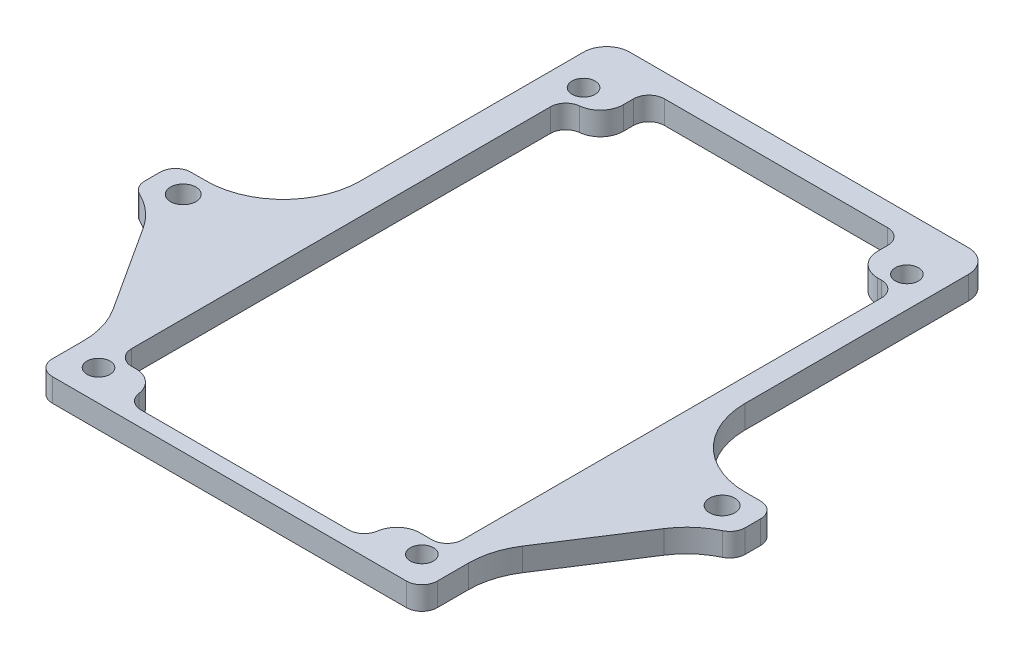
from build123d import *

# Parameters (mm, degrees)
SKETCH_1_R          = 1.65
SKETCH_1_R_2        = 1.5
EXTRUDE_1_DEPTH     = 3
FILLET_1_R          = 2
EXTRUDE_2_DEPTH     = 3
FILLET_2_R          = 10
SKETCH_3_W          = 43
SKETCH_3_H          = 4
EXTRUDE_3_DEPTH     = 3
FILLET_3_R          = 5
SKETCH_4_W          = 43
SKETCH_4_H          = 19.849699933
CUT_EXTRUDE_1_DEPTH = 10
FILLET_4_R          = 3
FILLET_5_R          = 3
FILLET_6_R          = 3
FILLET_7_R          = 3


with BuildPart() as part:
    # 草图1 → 凸台-拉伸1 (new body)
    with BuildSketch(Plane(origin=(0, 0, 0), x_dir=(1, 0, 0), z_dir=(0, 1, 0))):
        with BuildLine():
            Line((-37, 3), (-35, 3))
            ThreePointArc((-35, 3), (-27.928932188, 5.928932188), (-25, 13))
            Line((-25, 13), (-25, 42))
            ThreePointArc((-25, 42), (-24.121320344, 44.121320344), (-22, 45))
            Line((-22, 45), (22, 45))
            ThreePointArc((22, 45), (24.121320344, 44.121320344), (25, 42))
            Line((25, 42), (25, 13))
            ThreePointArc((25, 13), (27.928932188, 5.928932188), (35, 3))
            Line((35, 3), (37, 3))
            ThreePointArc((37, 3), (38.414213562, 2.414213562), (39, 1))
            Line((39, 1), (39, -1))
            ThreePointArc((39, -1), (38.414213562, -2.414213562), (37, -3))
            Line((37, -3), (35, -3))
            ThreePointArc((35, -3), (27.928932188, -5.928932188), (25, -13))
            Line((25, -13), (25, -27))
            ThreePointArc((25, -27), (24.414213562, -28.414213562), (23, -29))
            Line((23, -29), (-0.329591816, -29))
            Line((-0.329591816, -29), (-23, -29))
            ThreePointArc((-23, -29), (-24.414213562, -28.414213562), (-25, -27))
            Line((-25, -27), (-25, -13))
            ThreePointArc((-25, -13), (-27.928932188, -5.928932188), (-35, -3))
            Line((-35, -3), (-37, -3))
            ThreePointArc((-37, -3), (-38.414213562, -2.414213562), (-39, -1))
            Line((-39, -1), (-39, 1))
            ThreePointArc((-39, 1), (-38.414213562, 2.414213562), (-37, 3))
        make_face()
        with Locations((35, 0)):
            Circle(SKETCH_1_R, mode=Mode.SUBTRACT)
        with Locations((-35, 0)):
            Circle(SKETCH_1_R, mode=Mode.SUBTRACT)
        with Locations((21, 38)):
            Circle(SKETCH_1_R_2, mode=Mode.SUBTRACT)
        with Locations((21, -25)):
            Circle(SKETCH_1_R_2, mode=Mode.SUBTRACT)
        with Locations((-21, 38)):
            Circle(SKETCH_1_R_2, mode=Mode.SUBTRACT)
        with Locations((-21, -25)):
            Circle(SKETCH_1_R_2, mode=Mode.SUBTRACT)
        Polygon((-16.5, 42), (16.5, 42), (16.5, 35.7), (22, 35.7), (22, -22.7), (15.5, -22.7), (15.5, -27), (-15.5, -27), (-15.5, -22.7), (-21, -22.7), (-21, 35.7), (-16.5, 35.7), align=None, mode=Mode.SUBTRACT)
    extrude(amount=EXTRUDE_1_DEPTH)

    # 圆角1
    fillet_1_edges = [part.edges().sort_by_distance(p)[0] for p in [
        (-16.5, 1.5, -42),
        (-21, 1.5, -35.7),
        (-21, 1.5, 22.7),
        (-15.5, 1.5, 27),
        (15.5, 1.5, 27),
        (22, 1.5, 22.7),
        (22, 1.5, -35.7),
        (16.5, 1.5, -42),
    ]]
    fillet(fillet_1_edges, radius=FILLET_1_R)

    # 草图2 → 凸台-拉伸2 (add)
    with BuildSketch(Plane(origin=(0, 3, 0), x_dir=(1, 0, 0), z_dir=(0, 1, 0))):
        with BuildLine():
            Line((36, -3), (25, -20))
            Line((25, -20), (25, -13))
            ThreePointArc((25, -13), (27.928932188, -5.928932188), (35, -3))
            Line((35, -3), (36, -3))
        make_face()
        with BuildLine():
            Line((-25, -13), (-25, -20))
            Line((-25, -20), (-36, -3))
            Line((-36, -3), (-35, -3))
            ThreePointArc((-35, -3), (-27.928932188, -5.928932188), (-25, -13))
        make_face()
    extrude(amount=-EXTRUDE_2_DEPTH)

    # 圆角2
    fillet_2_edges = [part.edges().sort_by_distance(p)[0] for p in [
        (36, 1.5, 3),
        (25, 1.5, 20),
        (-36, 1.5, 3),
        (-25, 1.5, 20),
    ]]
    fillet(fillet_2_edges, radius=FILLET_2_R)

    # 草图3 → 凸台-拉伸3 (add)
    with BuildSketch(Plane(origin=(0, 3, 0), x_dir=(1, 0, 0), z_dir=(0, 1, 0))):
        with Locations((0.5, 8.5)):
            Rectangle(SKETCH_3_W, SKETCH_3_H)
    extrude(amount=-EXTRUDE_3_DEPTH)

    # 圆角3
    fillet_3_edges = [part.edges().sort_by_distance(p)[0] for p in [
        (-21, 1.5, -6.5),
        (22, 1.5, -6.5),
        (22, 1.5, -10.5),
        (-21, 1.5, -10.5),
    ]]
    fillet(fillet_3_edges, radius=FILLET_3_R)

    # 草图4 → 切除-拉伸1 (cut)
    with BuildSketch(Plane(origin=(0, 3, 0), x_dir=(1, 0, 0), z_dir=(0, 1, 0))):
        with Locations((0.5, 9.924849967)):
            Rectangle(SKETCH_4_W, SKETCH_4_H)
    extrude(amount=-CUT_EXTRUDE_1_DEPTH, mode=Mode.SUBTRACT)

    # 圆角4
    fillet_4_edges = [part.edges().sort_by_distance(p)[0] for p in [
        (16.5, 1.5, -35.7),
    ]]
    fillet(fillet_4_edges, radius=FILLET_4_R)

    # 圆角5
    fillet_5_edges = [part.edges().sort_by_distance(p)[0] for p in [
        (-16.5, 1.5, -35.7),
    ]]
    fillet(fillet_5_edges, radius=FILLET_5_R)

    # 圆角6
    fillet_6_edges = [part.edges().sort_by_distance(p)[0] for p in [
        (-15.5, 1.5, 22.7),
    ]]
    fillet(fillet_6_edges, radius=FILLET_6_R)

    # 圆角7
    fillet_7_edges = [part.edges().sort_by_distance(p)[0] for p in [
        (15.5, 1.5, 22.7),
    ]]
    fillet(fillet_7_edges, radius=FILLET_7_R)


solid = part.part
